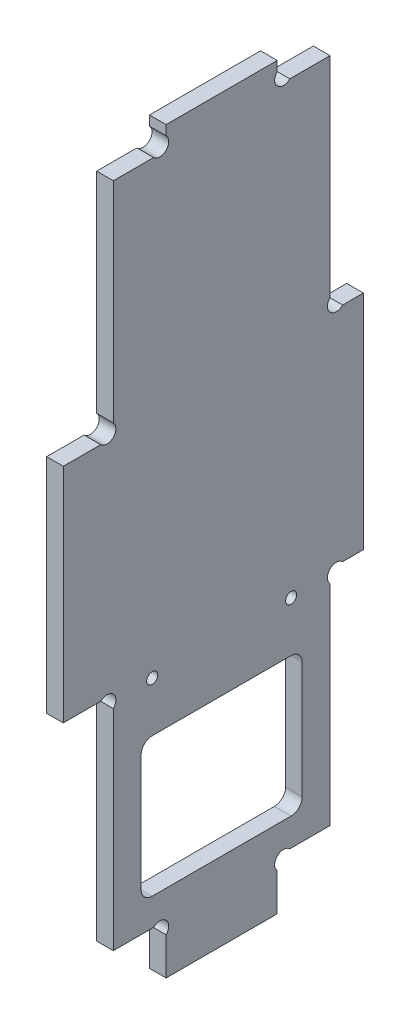
from build123d import *

# Parameters (mm, degrees)
EXTRUSION1_DEPTH        = 3
ESQUISSE2_W             = 29
ESQUISSE2_H             = 25
ENL_V_MAT_EXTRU_1_DEPTH = 4
CONG_1_R                = 2
ESQUISSE3_R             = 1
ENL_V_MAT_EXTRU_2_DEPTH = 4


with BuildPart() as part:
    # Esquisse1 → Extrusion1 (new body)
    with BuildSketch(Plane(origin=(0, 0, 0), x_dir=(0, 0, -1), z_dir=(1, 0, 0))):
        with BuildLine():
            Line((18.5, 6.7372583), (18.5, 0))
            Line((18.5, 0), (38.5, 0))
            Line((38.5, 0), (38.5, 6.7372583))
            ThreePointArc((38.5, 6.7372583), (38.5, 9), (40.7627417, 9))
            Line((40.7627417, 9), (48, 9))
            Line((48, 9), (48, 46.7372583))
            ThreePointArc((48, 46.7372583), (48, 49), (50.2627417, 49))
            Line((50.2627417, 49), (54, 49))
            Line((54, 49), (54, 89))
            Line((54, 89), (50.2627417, 89))
            ThreePointArc((50.2627417, 89), (48, 89), (48, 91.2627417))
            Line((48, 91.2627417), (48, 129))
            Line((48, 129), (40.7627417, 129))
            ThreePointArc((40.7627417, 129), (38.5, 129), (38.5, 131.2627417))
            Line((38.5, 131.2627417), (38.5, 133))
            Line((38.5, 133), (18.5, 133))
            Line((18.5, 133), (18.5, 131.2627417))
            ThreePointArc((18.5, 131.2627417), (18.5, 129), (16.2372583, 129))
            Line((16.2372583, 129), (9, 129))
            Line((9, 129), (9, 91.2627417))
            ThreePointArc((9, 91.2627417), (9, 89), (6.7372583, 89))
            Line((6.7372583, 89), (0, 89))
            Line((0, 89), (0, 49))
            Line((0, 49), (6.7372583, 49))
            ThreePointArc((6.7372583, 49), (9, 49), (9, 46.7372583))
            Line((9, 46.7372583), (9, 9))
            Line((9, 9), (16.2372583, 9))
            ThreePointArc((16.2372583, 9), (18.5, 9), (18.5, 6.7372583))
        make_face()
    extrude(amount=EXTRUSION1_DEPTH)

    # Esquisse2 → Enlèv. mat.-Extru.1 (cut, through all)
    with BuildSketch(Plane(origin=(3, 0, 0), x_dir=(0, 0, -1), z_dir=(1, 0, 0))):
        with Locations((28.5, 26.5)):
            Rectangle(ESQUISSE2_W, ESQUISSE2_H)
    extrude(amount=-ENL_V_MAT_EXTRU_1_DEPTH, mode=Mode.SUBTRACT)

    # Congé1
    cong_1_edges = [part.edges().sort_by_distance(p)[0] for p in [
        (1.5, 14, -14),
        (1.5, 39, -14),
        (1.5, 39, -43),
        (1.5, 14, -43),
    ]]
    fillet(cong_1_edges, radius=CONG_1_R)

    # Esquisse3 → Enlèv. mat.-Extru.2 (cut, through all)
    with BuildSketch(Plane(origin=(3, 0, 0), x_dir=(0, 0, -1), z_dir=(1, 0, 0))):
        with Locations((16, 48)):
            Circle(ESQUISSE3_R)
        with Locations((41, 48)):
            Circle(ESQUISSE3_R)
    extrude(amount=-ENL_V_MAT_EXTRU_2_DEPTH, mode=Mode.SUBTRACT)


solid = part.part
